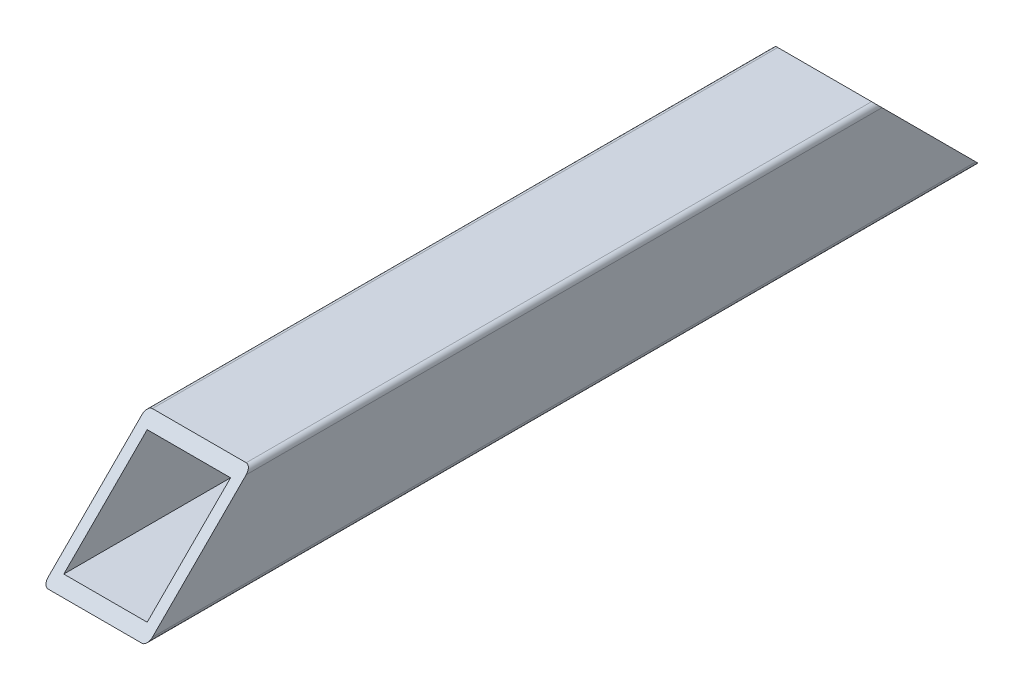
from build123d import *

# Parameters (mm, degrees)
SKETCH_11_W          = 8
SKETCH_11_H          = 8
MEMBER_10_10_1_DEPTH = 80
CUT_EXTRUDE_1_DEPTH  = 5


with BuildPart() as part:
    # 草图11 → Member 10_10_1 (new body)
    with BuildSketch(Plane.YX):
        with BuildLine():
            Line((-4.5, -5), (4.5, -5))
            ThreePointArc((4.5, -5), (4.853553391, -4.853553391), (5, -4.5))
            Line((5, -4.5), (5, 4.5))
            ThreePointArc((5, 4.5), (4.853553391, 4.853553391), (4.5, 5))
            Line((4.5, 5), (-4.5, 5))
            ThreePointArc((-4.5, 5), (-4.853553391, 4.853553391), (-5, 4.5))
            Line((-5, 4.5), (-5, -4.5))
            ThreePointArc((-5, -4.5), (-4.853553391, -4.853553391), (-4.5, -5))
        make_face()
        Rectangle(SKETCH_11_W, SKETCH_11_H, mode=Mode.SUBTRACT)
    extrude(amount=MEMBER_10_10_1_DEPTH)

    # 草图12 → 切除-拉伸1 (cut, symmetric)
    with BuildSketch(Plane(origin=(0, 0, 0), x_dir=(0, 0, -1), z_dir=(1, 0, 0))):
        Polygon((0, -5), (0, 5), (10, 5), align=None)
        Polygon((80, -5), (80, 5), (70, 5), align=None)
    extrude(amount=CUT_EXTRUDE_1_DEPTH, both=True, mode=Mode.SUBTRACT)


solid = part.part
